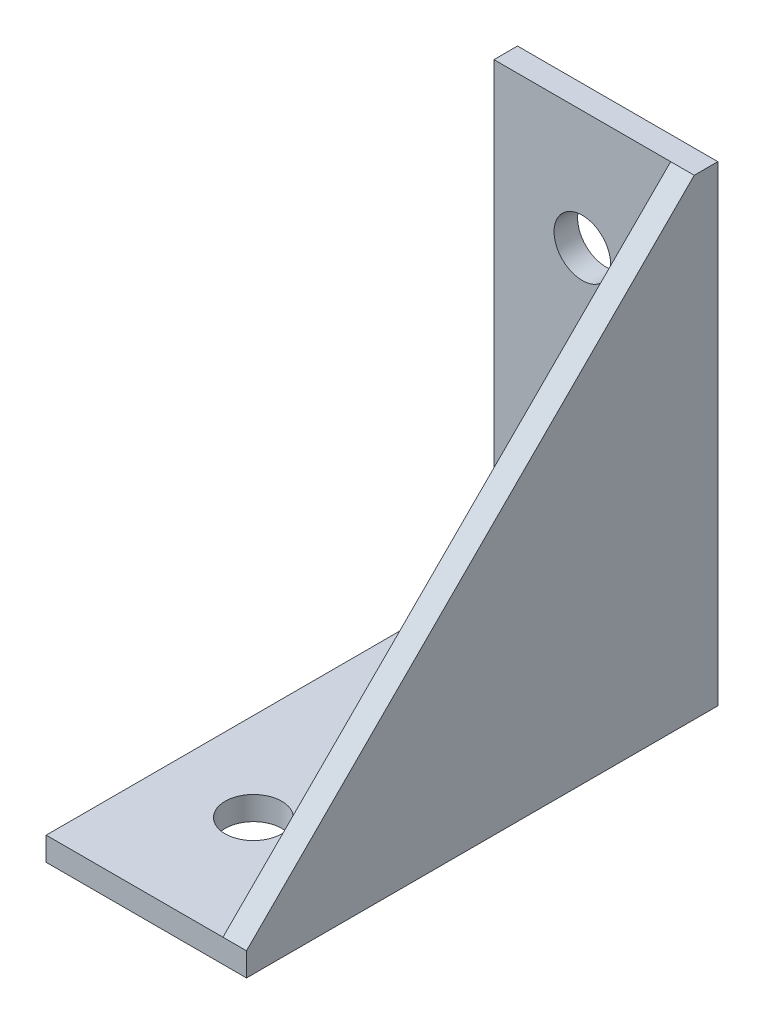
from build123d import *

# Parameters (mm, degrees)
BOSS_EXTRUDE1_DEPTH      = 2
BOSS_EXTRUDE2_DEPTH      = 17
SKETCH3_R                = 2.1
M4_CLEARANCE_HOLE1_D     = 4.8
M4_CLEARANCE_HOLE1_DEPTH = 2
M4_CLEARANCE_HOLE2_D     = 4.8
M4_CLEARANCE_HOLE2_DEPTH = 2


with BuildPart() as part:
    # Sketch1 → Boss-Extrude1 (new body)
    with BuildSketch(Plane(origin=(0, 0, 0), x_dir=(0, 0, -1), z_dir=(1, 0, 0))):
        Polygon((-38, 0), (0, 0), (0, 38), align=None)
    extrude(amount=BOSS_EXTRUDE1_DEPTH)

    # Sketch2 → Boss-Extrude2 (add)
    with BuildSketch(Plane(origin=(2, 0, 0), x_dir=(0, 0, -1), z_dir=(1, 0, 0))):
        Polygon((0, 38), (2, 38), (2, -2), (-38, -2), (-38, 0), (0, 0), align=None)
    extrude(amount=-BOSS_EXTRUDE2_DEPTH)

    # Sketch3 → Cut-Revolve1 (revolve, cut)
    with BuildSketch(Plane(origin=(0, 0, 0), x_dir=(1, 0, 0), z_dir=(0, 1, 0))):
        with Locations((-7.5, -10.089030863)):
            Circle(SKETCH3_R)
        with Locations((-7.5, -27.910969137)):
            Circle(SKETCH3_R)
    revolve(axis=Axis((-15, 0, 0), (1, 0, 0)), mode=Mode.SUBTRACT)

    # M4 Clearance Hole1
    with Locations(Plane.XY):
        with Locations((-7.5, 27.910969137), (-7.5, 10.089030863)):
            Hole(M4_CLEARANCE_HOLE1_D / 2, depth=M4_CLEARANCE_HOLE1_DEPTH)

    # M4 Clearance Hole2
    with Locations(Plane(origin=(0, 0, 0), x_dir=(1, 0, 0), z_dir=(0, 1, 0))):
        with Locations((-7.5, -10.089030863), (-7.5, -27.910969137)):
            Hole(M4_CLEARANCE_HOLE2_D / 2, depth=M4_CLEARANCE_HOLE2_DEPTH)


solid = part.part
